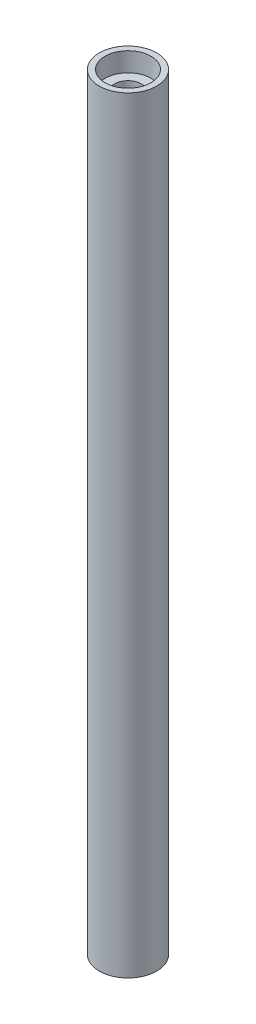
from build123d import *

# Parameters (mm, degrees)
SKETCH_1_R          = 7.5
EXTRUDE_1_DEPTH     = 200
SKETCH_2_R          = 3.5
CUT_EXTRUDE_1_DEPTH = 201
SKETCH_4_R          = 6
CUT_EXTRUDE_3_DEPTH = 5
SKETCH_7_R          = 6
CUT_EXTRUDE_4_DEPTH = 5


with BuildPart() as part:
    # Эскиз1 → Бобышка-Вытянуть1 (new body)
    with BuildSketch(Plane(origin=(0, 0, 0), x_dir=(1, 0, 0), z_dir=(0, 1, 0))):
        Circle(SKETCH_1_R)
    extrude(amount=EXTRUDE_1_DEPTH)

    # Эскиз2 → Вырез-Вытянуть1 (cut, through all)
    with BuildSketch(Plane(origin=(0, 200, 0), x_dir=(1, 0, 0), z_dir=(0, 1, 0))):
        Circle(SKETCH_2_R)
    extrude(amount=-CUT_EXTRUDE_1_DEPTH, mode=Mode.SUBTRACT)

    # Эскиз4 → Вырез-Вытянуть3 (cut)
    with BuildSketch(Plane(origin=(0, 200, 0), x_dir=(1, 0, 0), z_dir=(0, 1, 0))):
        Circle(SKETCH_4_R)
    extrude(amount=-CUT_EXTRUDE_3_DEPTH, mode=Mode.SUBTRACT)

    # Эскиз7 → Вырез-Вытянуть4 (cut)
    with BuildSketch(Plane.XZ):
        Circle(SKETCH_7_R)
    extrude(amount=-CUT_EXTRUDE_4_DEPTH, mode=Mode.SUBTRACT)


solid = part.part
